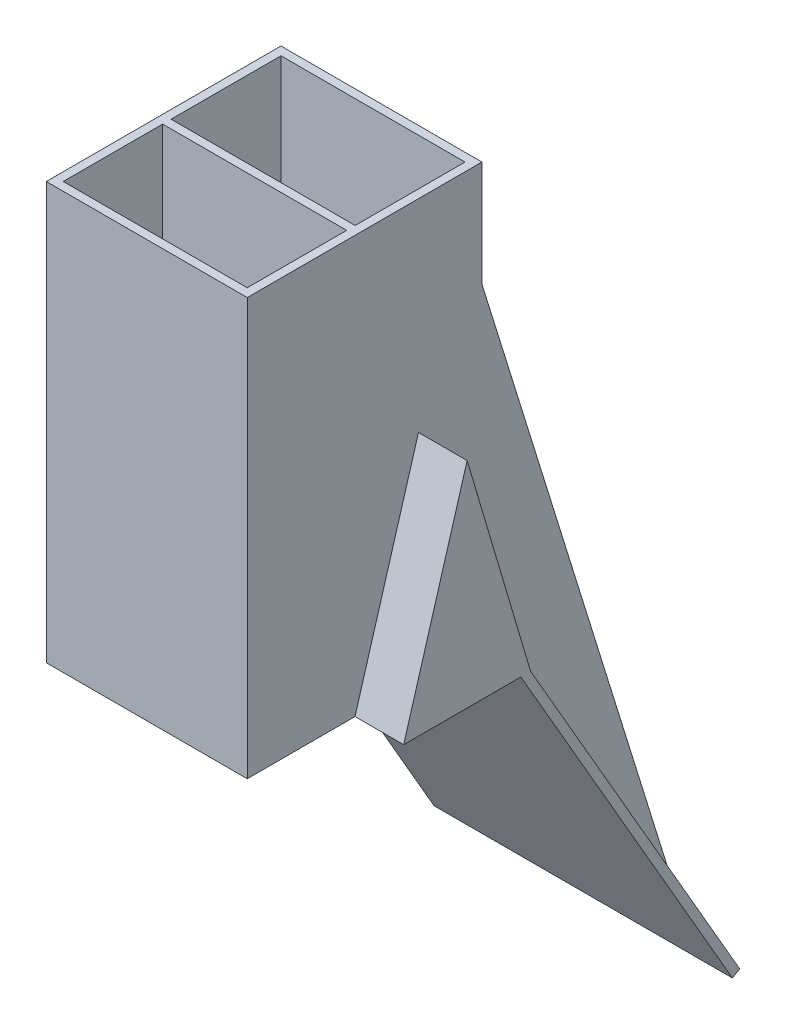
from build123d import *

# Parameters (mm, degrees)
SKIZZE1_W                       = 9.5
SKIZZE1_H                       = 11.093
SKIZZE1_W_2                     = 8.7
SKIZZE1_H_2                     = 4.7
SKIZZE1_H_3                     = 5.193
AUFSATZ_LINEAR_AUSTRAGEN1_DEPTH = 19.7
AUFSATZ_LINEAR_AUSTRAGEN2_DEPTH = 2.3
SCHNITT_LINEAR_AUSTRAGEN1_DEPTH = 13.7
SKIZZE4_W                       = 13.3
SKIZZE4_H                       = 5.193
SCHNITT_LINEAR_AUSTRAGEN2_DEPTH = 0.4
AUFSATZ_LINEAR_AUSTRAGEN3_DEPTH = 14.1
AUFSATZ_LINEAR_START            = -9.5
AUFSATZ_LINEAR_AUSTRAGEN4_DEPTH = 9.5


with BuildPart() as part:
    # Skizze1 → Aufsatz-Linear austragen1 (new body)
    with BuildSketch(Plane(origin=(0, 0, 0), x_dir=(1, 0, 0), z_dir=(0, 1, 0))):
        with Locations((4.75, 5.5465)):
            Rectangle(SKIZZE1_W, SKIZZE1_H)
        with Locations((4.75, 2.75)):
            Rectangle(SKIZZE1_W_2, SKIZZE1_H_2, mode=Mode.SUBTRACT)
        with Locations((4.75, 8.0965)):
            Rectangle(SKIZZE1_W_2, SKIZZE1_H_3, mode=Mode.SUBTRACT)
    extrude(amount=AUFSATZ_LINEAR_AUSTRAGEN1_DEPTH)

    # Skizze2 → Aufsatz-Linear austragen2 (add)
    with BuildSketch(Plane.ZY):
        Polygon((-11.093, 0), (-8.093, 10.13), (-5.093, 0), align=None)
    aufsatz_linear_austragen2 = extrude(amount=AUFSATZ_LINEAR_AUSTRAGEN2_DEPTH)

    # Spiegeln1: Aufsatz-Linear austragen2 across plane
    add(aufsatz_linear_austragen2.mirror(Plane(origin=(4.75, 0, 0), x_dir=(0, 0, 1), z_dir=(1, 0, 0))))

    # Skizze3 → Schnitt-Linear austragen1 (cut)
    with BuildSketch(Plane.ZY.offset(2.3)):
        Polygon((-10.379677593, 1), (-5.806322407, 1), (-8.093, 8.721348004), align=None)
    extrude(amount=-SCHNITT_LINEAR_AUSTRAGEN1_DEPTH, mode=Mode.SUBTRACT)

    # Skizze4 → Schnitt-Linear austragen2 (cut)
    with BuildSketch(Plane.XZ):
        with Locations((4.75, -8.0965)):
            Rectangle(SKIZZE4_W, SKIZZE4_H)
    extrude(amount=-SCHNITT_LINEAR_AUSTRAGEN2_DEPTH, mode=Mode.SUBTRACT)

    # Skizze5 → Aufsatz-Linear austragen3 (add)
    with BuildSketch(Plane.ZY.offset(2.3)):
        Polygon((-20.977529946, -17.120508076), (-20.631119785, -17.320508076), (-10.631119785, 0), (-11.093, 0), align=None)
    extrude(amount=-AUFSATZ_LINEAR_AUSTRAGEN3_DEPTH)

    # Skizze6 → Aufsatz-Linear austragen4 (add)
    with BuildSketch(Plane.ZY.offset(AUFSATZ_LINEAR_START)):
        Polygon((-20.977529946, -17.120508076), (-11.093, 0), (-11.093, 14.7), align=None)
    extrude(amount=AUFSATZ_LINEAR_AUSTRAGEN4_DEPTH)


solid = part.part
